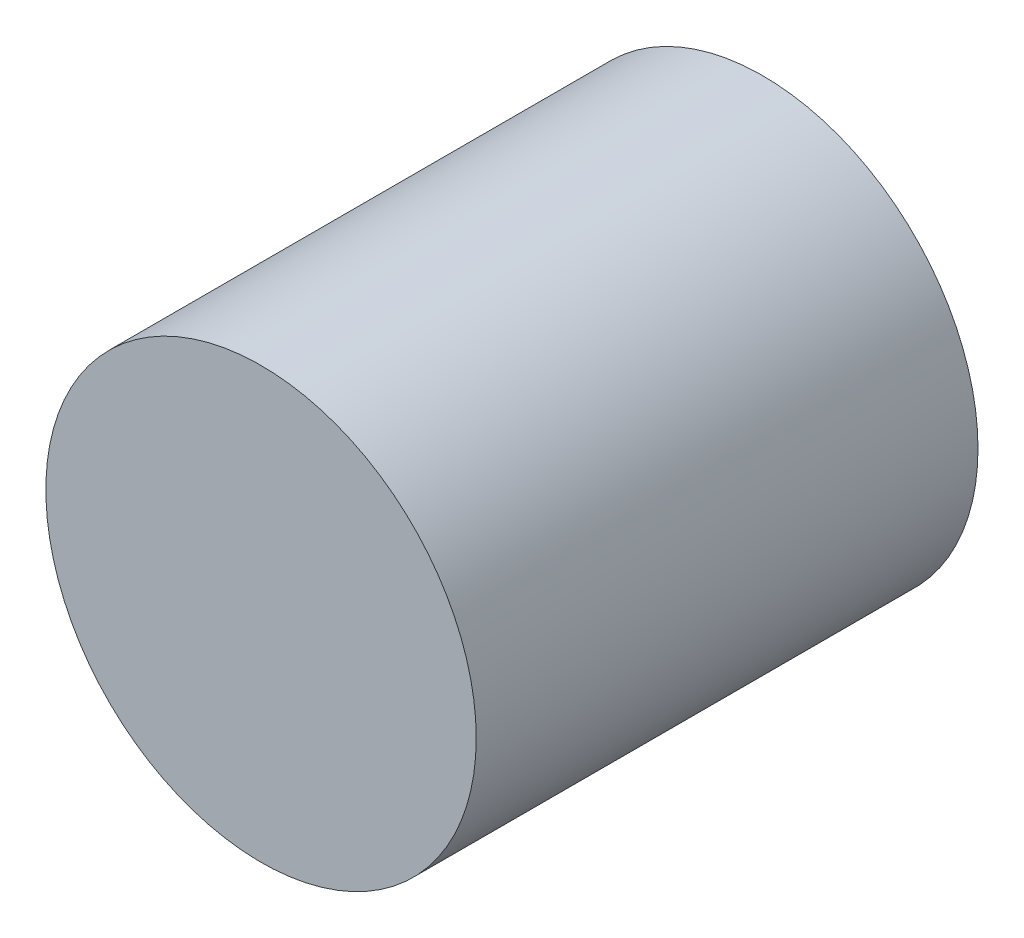
from build123d import *

# Parameters (mm, degrees)
SKETCH1_R           = 6.35
BOSS_EXTRUDE1_DEPTH = 14.806056413


with BuildPart() as part:
    # Sketch1 → Boss-Extrude1 (new body)
    with BuildSketch(Plane.XY):
        Circle(SKETCH1_R)
    extrude(amount=BOSS_EXTRUDE1_DEPTH)


solid = part.part
